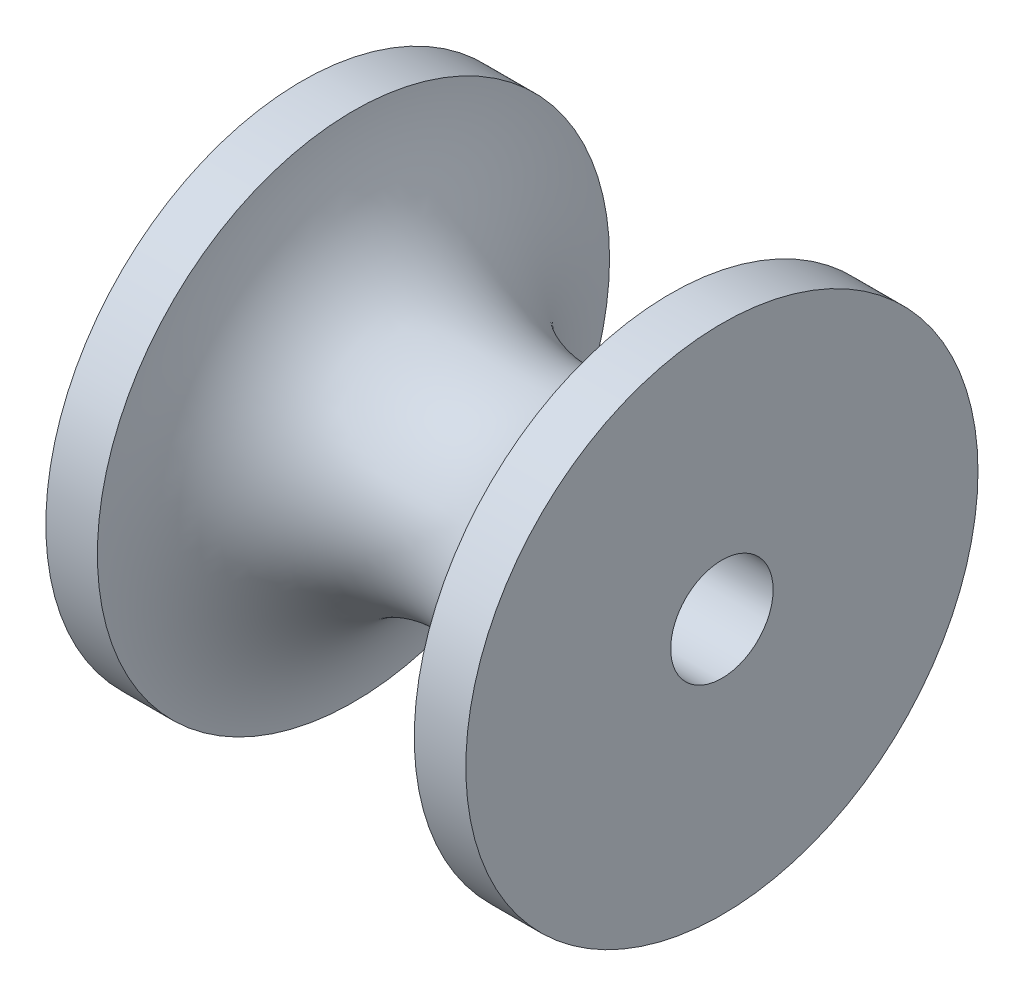
from build123d import *


with BuildPart() as part:
    # Sketch1 → Revolve1 (revolve)
    with BuildSketch(Plane.XY):
        with BuildLine():
            Line((4.1, 1), (-4.1, 1))
            Line((-4.1, 1), (-4.1, 5))
            Line((-4.1, 5), (-3.09354166, 5))
            ThreePointArc((-3.09354166, 5), (0, 2.1), (3.09354166, 5))
            Line((3.09354166, 5), (4.1, 5))
            Line((4.1, 5), (4.1, 1))
        make_face()
    revolve(axis=Axis((11.857261887, 0, 0), (-1, 0, 0)))


solid = part.part
